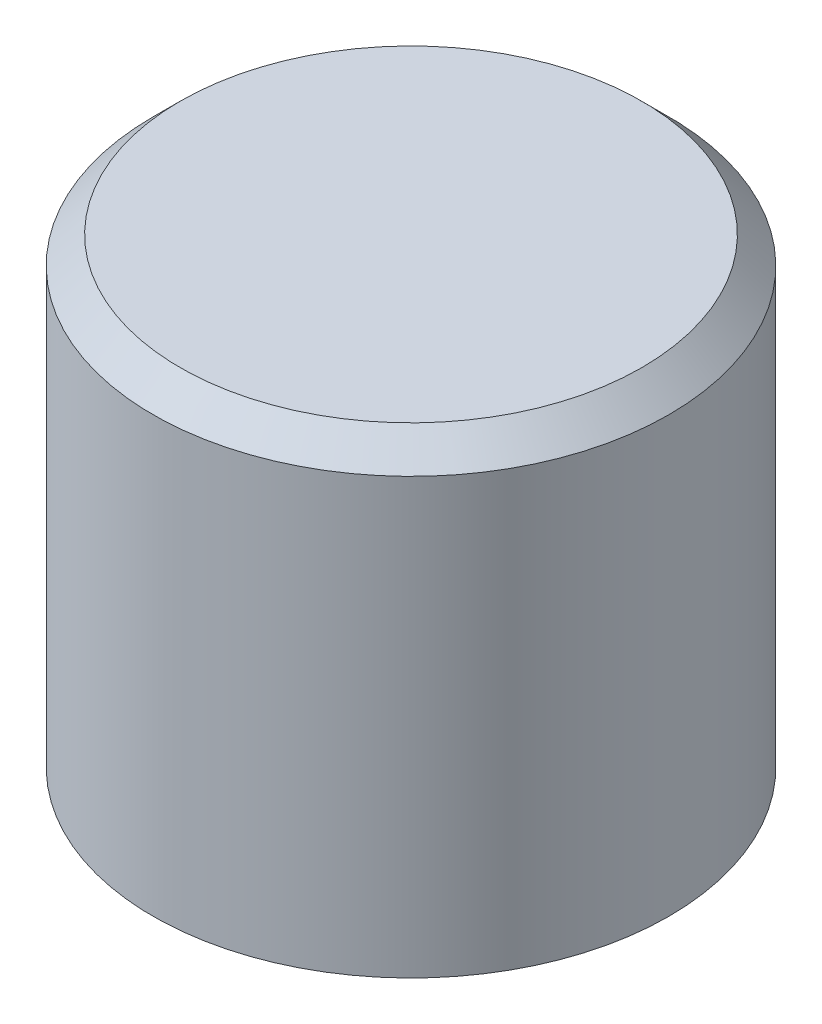
from build123d import *

# Parameters (mm, degrees)
SKETCH2_R          = 3.175
CUT_EXTRUDE1_DEPTH = 7
CUT_EXTRUDE2_REACH = 11.5
SKETCH3_R          = 1.1303


with BuildPart() as part:
    # Sketch1 → Revolve1 (revolve)
    with BuildSketch(Plane.XY):
        Polygon((0, 8.5), (8.5, 8.5), (9.5, 7.5), (9.5, -8.5), (8.5, -8.5), (8.5, -3.5), (5.5, -0.5), (0, -0.5), align=None)
    revolve(axis=Axis((0, 8.5, 0), (0, -1, 0)))

    # Sketch2 → Cut-Extrude1 (cut)
    with BuildSketch(Plane.XZ.offset(0.5)):
        Circle(SKETCH2_R)
    extrude(amount=-CUT_EXTRUDE1_DEPTH, mode=Mode.SUBTRACT)

    # Sketch3 → Cut-Extrude2 (cut, up to next)
    with BuildSketch(Plane.XY, mode=Mode.PRIVATE) as cut_extrude2_sk1:
        with Locations((0, 2.5)):
            Circle(SKETCH3_R)
    cut_extrude2_tool1 = extrude(cut_extrude2_sk1.sketch, amount=-CUT_EXTRUDE2_REACH, mode=Mode.PRIVATE) & part.part
    add(cut_extrude2_tool1.solids().sort_by_distance((0, 2.5, 0))[0], mode=Mode.SUBTRACT)


solid = part.part
